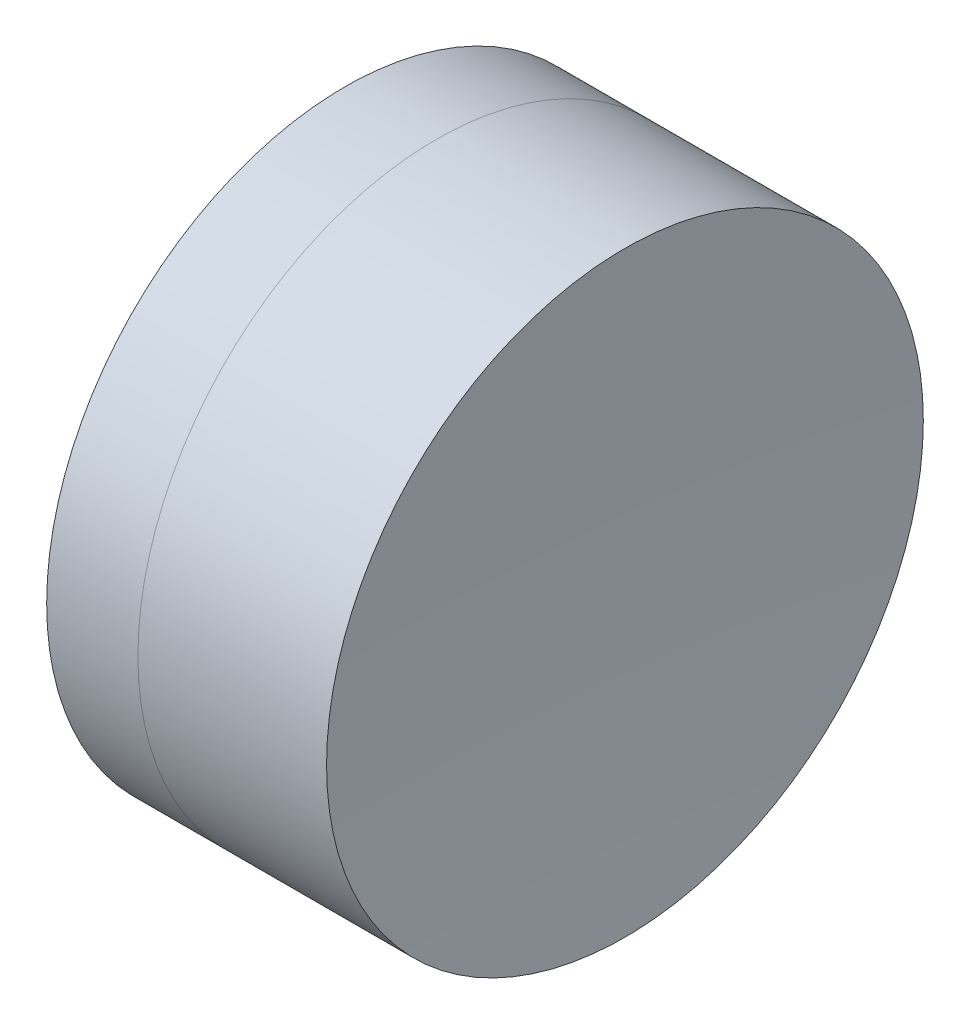
from build123d import *


with BuildPart() as part:
    # 草图1 one side → 旋转1 (revolve)
    with BuildSketch(Plane(origin=(0, 0, 0), x_dir=(1, 0, 0), z_dir=(0, 1, 0)), mode=Mode.PRIVATE) as revolve_1_sk:
        with BuildLine():
            ThreePointArc((21.876158472, 4), (21.008410623, 2.083085973), (20.711259903, 0))
            Line((20.711259903, 0), (24.211259903, 0))
            ThreePointArc((24.211259903, 0), (23.928075906, 2.075851339), (23.099218927, 4))
            Line((23.099218927, 4), (21.876158472, 4))
        make_face()
    revolve(revolve_1_sk.sketch.rotate(Axis((-0.816062176, 0, 0), (1, 0, 0)), 180), axis=Axis((-0.816062176, 0, 0), (1, 0, 0)))  # turned: the seam where the file's is


with BuildPart() as body_2:
    # 草图2 one side → 旋转2 (revolve)
    with BuildSketch(Plane(origin=(0, 0, 0), x_dir=(1, 0, 0), z_dir=(0, 1, 0))):
        with BuildLine():
            Line((25.62807962, 4), (23.099218927, 4))
            ThreePointArc((23.099218927, 4), (23.928075906, 2.075851339), (24.211259903, 0))
            Line((24.211259903, 0), (25.511259903, 0))
            ThreePointArc((25.511259903, 0), (25.540471057, 2.000852746), (25.62807962, 4))
        make_face()
    revolve(axis=Axis((-0.551919993, 0, 0), (1, 0, 0)))


solid = Compound([part.part, body_2.part])
